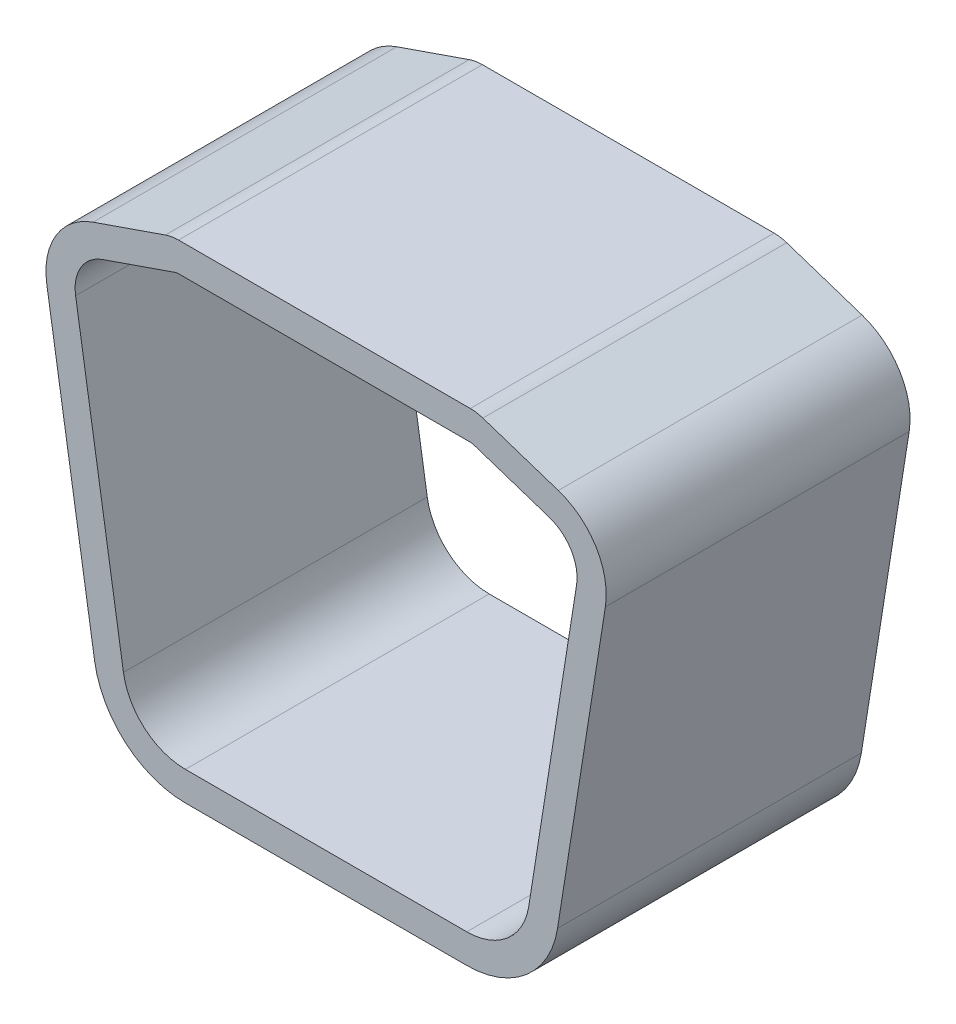
from build123d import *

# Parameters (mm, degrees)
EXTRUDE_1_DEPTH = 27.6


with BuildPart() as part:
    # 草图1 → 凸台-拉伸1 (new body)
    with BuildSketch(Plane.XY):
        with BuildLine():
            Line((13.366208682, 26.400087715), (20.217636418, 24.133453872))
            ThreePointArc((20.217636418, 24.133453872), (23.645978989, 21.408723367), (24.49520491, 17.112619964))
            Line((24.49520491, 17.112619964), (20.150640538, -10.351388685))
            ThreePointArc((20.150640538, -10.351388685), (17.326686466, -15.395594315), (11.903196789, -17.396715696))
            Line((11.903196789, -17.396715696), (-13.656803211, -17.396715696))
            ThreePointArc((-13.656803211, -17.396715696), (-19.080292887, -15.395594315), (-21.90424696, -10.351388685))
            Line((-21.90424696, -10.351388685), (-26.248811331, 17.112619964))
            ThreePointArc((-26.248811331, 17.112619964), (-25.422376853, 21.371021729), (-22.054699947, 24.105200178))
            Line((-22.054699947, 24.105200178), (-15.474583087, 26.383847403))
            ThreePointArc((-15.474583087, 26.383847403), (-14.885785491, 26.534208607), (-14.280201498, 26.584796429))
            Line((-14.280201498, 26.584796429), (12.219798502, 26.584796429))
            ThreePointArc((12.219798502, 26.584796429), (12.800395955, 26.538323396), (13.366208682, 26.400087715))
        make_face()
        with BuildLine():
            Line((12.533883483, 23.884191302), (19.385311219, 21.617557459))
            ThreePointArc((19.385311219, 21.617557459), (21.38292815, 20.029919212), (21.877752702, 17.526677859))
            Line((21.877752702, 17.526677859), (17.53318833, -9.93733079))
            ThreePointArc((17.53318833, -9.93733079), (15.605459203, -13.380680741), (11.903196789, -14.746715696))
            Line((11.903196789, -14.746715696), (-13.656803211, -14.746715696))
            ThreePointArc((-13.656803211, -14.746715696), (-17.359065624, -13.380680741), (-19.286794752, -9.93733079))
            Line((-19.286794752, -9.93733079), (-23.631359123, 17.526677859))
            ThreePointArc((-23.631359123, 17.526677859), (-23.149814624, 20.007951328), (-21.187546191, 21.601094677))
            Line((-21.187546191, 21.601094677), (-14.60742933, 23.879741901))
            ThreePointArc((-14.60742933, 23.879741901), (-14.446114921, 23.920936752), (-14.280201498, 23.934796429))
            Line((-14.280201498, 23.934796429), (12.219798502, 23.934796429))
            ThreePointArc((12.219798502, 23.934796429), (12.378866298, 23.922064091), (12.533883483, 23.884191302))
        make_face(mode=Mode.SUBTRACT)
    extrude(amount=EXTRUDE_1_DEPTH)


solid = part.part
